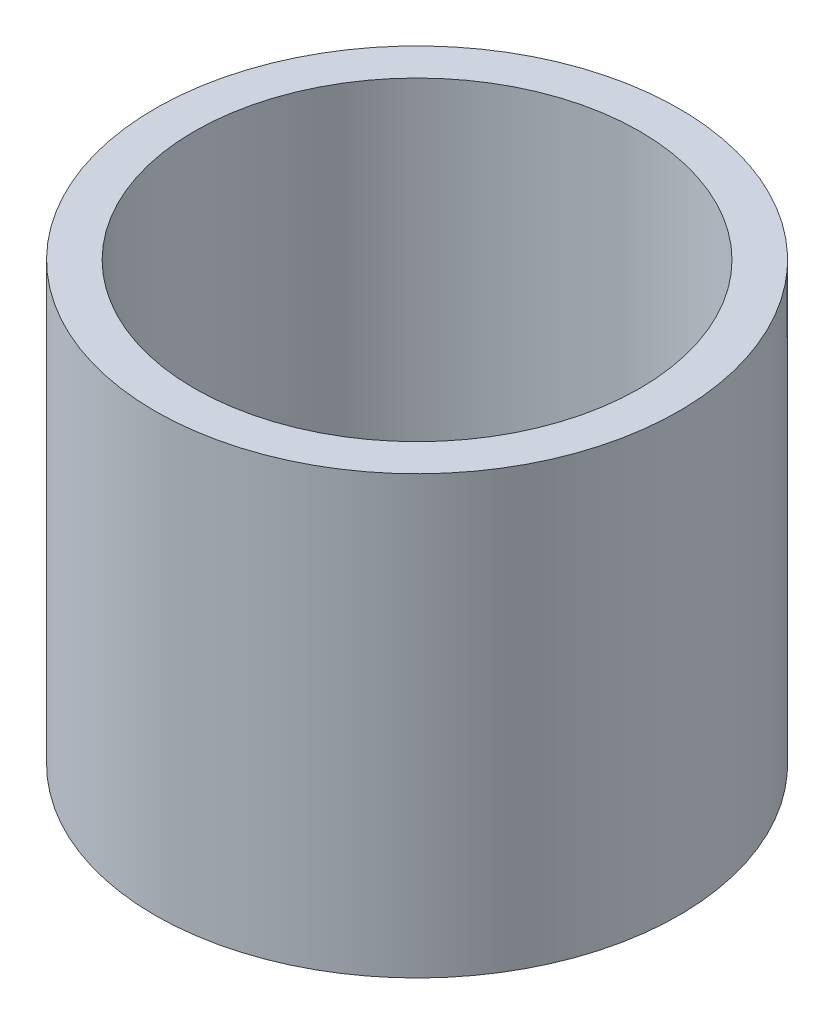
from build123d import *

# Parameters (mm, degrees)
SKETCH1_W          = 0.85
SKETCH1_H          = 5
SKETCH2_R          = 2.55
CUT_EXTRUDE1_DEPTH = 6


with BuildPart() as part:
    # Sketch1 → Revolve1 (revolve)
    with BuildSketch(Plane.XY):
        with Locations((2.575, 0)):
            Rectangle(SKETCH1_W, SKETCH1_H)
    revolve(axis=Axis((0, 9.8862121, 0), (0, -1, 0)))

    # Sketch2 → Cut-Extrude1 (cut, through all)
    with BuildSketch(Plane(origin=(0, 2.5, 0), x_dir=(1, 0, 0), z_dir=(0, 1, 0))):
        Circle(SKETCH2_R)
    extrude(amount=-CUT_EXTRUDE1_DEPTH, mode=Mode.SUBTRACT)


solid = part.part
